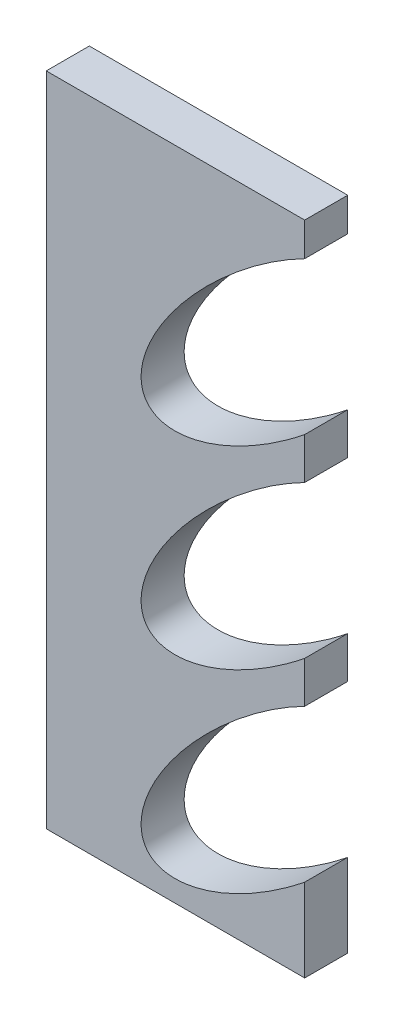
from build123d import *

# Parameters (mm, degrees)
BOSS_EXTRUDE7_DEPTH = 10


with BuildPart() as part:
    # Sketch3 → Boss-Extrude7 (new body)
    with BuildSketch(Plane.XY):
        with BuildLine():
            Line((18.897322572, 45.422931351), (-41.102677428, 45.422931351))
            Line((-41.102677428, 45.422931351), (-41.102677428, -106.977068649))
            Line((-41.102677428, -106.977068649), (18.897322572, -106.977068649))
            Line((18.897322572, -106.977068649), (18.897322572, -87.705066785))
            add(Edge.make_bspline(
                [(-17.594321294, -99.659211718), (-8.800569737, -109.995269515), (18.897322572, -87.705066785)],
                knots=[0, 0, 0, 1.49919268, 1.49919268, 1.49919268], degree=2, weights=[1, 0.73196396, 1]))
            add(Edge.make_bspline(
                [(18.897322572, -52.345562451), (-34.569356249, -79.706982994), (-17.594321294, -99.659211718)],
                knots=[4.157275572, 4.157275572, 4.157275572, 6.283185307, 6.283185307, 6.283185307], degree=2, weights=[1, 0.486292256, 1]))
            Line((18.897322572, -52.345562451), (18.897322572, -42.705066785))
            add(Edge.make_bspline(
                [(18.897322572, -7.345562451), (-19.086715764, -26.783785841), (-19.086715764, -50.028475828), (-19.086715764, -73.273165814), (18.897322572, -42.705066785)],
                knots=[1.015682918, 1.015682918, 1.015682918, 2.828234126, 2.828234126, 4.640785333, 4.640785333, 4.640785333], degree=2, weights=[1, 0.616681911, 1, 0.616681911, 1]))
            Line((18.897322572, -7.345562451), (18.897322572, 2.294933215))
            add(Edge.make_bspline(
                [(18.897322572, 37.654437549), (-19.086715764, 18.216214159), (-19.086715764, -5.028475828), (-19.086715764, -28.273165814), (18.897322572, 2.294933215)],
                knots=[1.015682918, 1.015682918, 1.015682918, 2.828234126, 2.828234126, 4.640785333, 4.640785333, 4.640785333], degree=2, weights=[1, 0.616681911, 1, 0.616681911, 1]))
            Line((18.897322572, 37.654437549), (18.897322572, 45.422931351))
        make_face()
    extrude(amount=BOSS_EXTRUDE7_DEPTH)


solid = part.part
